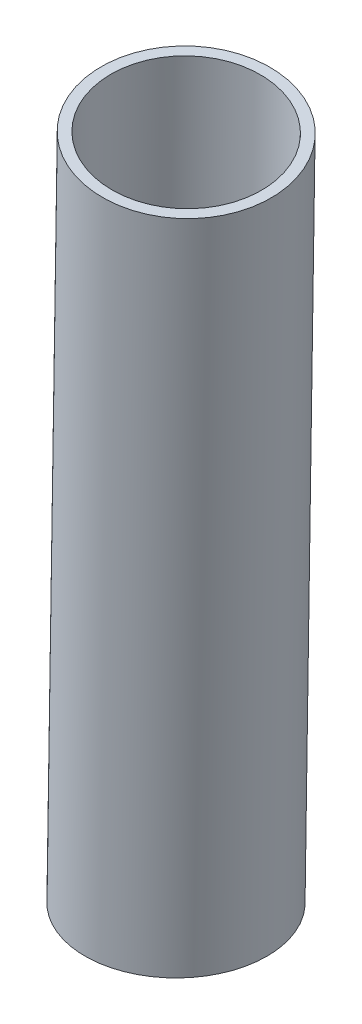
from build123d import *

# Parameters (mm, degrees)
SKIZZE5_W                            = 200
SKIZZE5_H                            = 50
SCHNITT_LINEAR_AUSTRAGEN1_DEPTH      = 80
SCHNITT_LINEAR_AUSTRAGEN1_DEPTH_BACK = 80


with BuildPart() as part:
    # Skizze4 → Rotation1 (revolve)
    with BuildSketch(Plane(origin=(0, 0, 0), x_dir=(1, 0, 0), z_dir=(0, -0.076022935, 0.997106069)), mode=Mode.PRIVATE) as rotation1_sk:
        Polygon((114.131092539, 578.096527722), (61.60099626, -5.544344847), (69.568788824, -6.261479185), (122.098885103, 577.379393384), align=None)
    revolve(rotation1_sk.sketch.rotate(Axis((0, 0, 0), (0.089641792, 0.99309179, 0.075716872)), 359.608411729), axis=Axis((0, 0, 0), (0.089641792, 0.99309179, 0.075716872)))  # turned: the seam where the file's is

    # Skizze5 → Schnitt-Linear austragen1 (cut, two sides)
    with BuildSketch(Plane.XY) as schnitt_linear_austragen1_sk:
        Rectangle(SKIZZE5_W, SKIZZE5_H)
    extrude(amount=SCHNITT_LINEAR_AUSTRAGEN1_DEPTH, mode=Mode.SUBTRACT)
    extrude(schnitt_linear_austragen1_sk.sketch, amount=-SCHNITT_LINEAR_AUSTRAGEN1_DEPTH_BACK, mode=Mode.SUBTRACT)


solid = part.part
